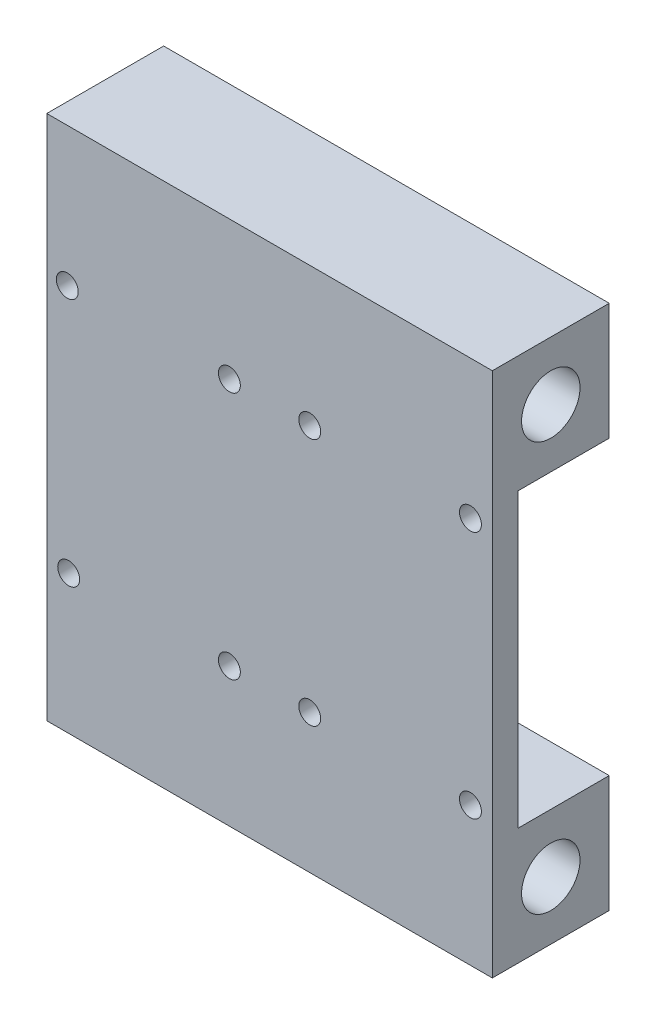
from build123d import *

# Parameters (mm, degrees)
BOSS_EXTRUDE1_DEPTH = 3.5
SKETCH5_W           = 16
SKETCH5_H           = 16
SKETCH5_R           = 4
BOSS_EXTRUDE2_DEPTH = 115
SKETCH8_R           = 1.5
CUT_EXTRUDE1_DEPTH  = 3.5
CUT_EXTRUDE2_DEPTH  = 16


with BuildPart() as part:
    # Sketch1 → Boss-Extrude1 (new body)
    with BuildSketch(Plane.XY):
        Polygon((0, 0), (0, 40), (115, 40), (115, 0), (110, 0), (60, 0), (55, 0), (5, 0), align=None)
    extrude(amount=BOSS_EXTRUDE1_DEPTH)

    # Sketch5 → Boss-Extrude2 (add)
    with BuildSketch(Plane(origin=(115, 0, 0), x_dir=(0, 0, -1), z_dir=(1, 0, 0))):
        with Locations((4.5, 48)):
            Rectangle(SKETCH5_W, SKETCH5_H)
        with Locations((4.5, 48)):
            Circle(SKETCH5_R, mode=Mode.SUBTRACT)
        with Locations((4.5, -8)):
            Rectangle(SKETCH5_W, SKETCH5_H)
        with Locations((4.5, -8)):
            Circle(SKETCH5_R, mode=Mode.SUBTRACT)
    extrude(amount=-BOSS_EXTRUDE2_DEPTH)

    # Sketch8 → Cut-Extrude1 (cut)
    with BuildSketch(Plane(origin=(0, 0, 0), x_dir=(-1, 0, 0), z_dir=(0, 0, -1))):
        with Locations((-107, 37)):
            Circle(SKETCH8_R)
        with Locations((-63, 37)):
            Circle(SKETCH8_R)
        with Locations((-52, 37)):
            Circle(SKETCH8_R)
        with Locations((-8, 37)):
            Circle(SKETCH8_R)
        with Locations((-8, 3)):
            Circle(SKETCH8_R)
        with Locations((-63, 3)):
            Circle(SKETCH8_R)
        with Locations((-52, 3)):
            Circle(SKETCH8_R)
        with Locations((-107, 3)):
            Circle(SKETCH8_R)
        with Locations((-85, 37)):
            Circle(SKETCH8_R)
        with Locations((-29.809705399, 37)):
            Circle(SKETCH8_R)
        with Locations((-30, 3)):
            Circle(SKETCH8_R)
        with Locations((-85, 3)):
            Circle(SKETCH8_R)
    extrude(amount=-CUT_EXTRUDE1_DEPTH, mode=Mode.SUBTRACT)

    # Sketch10 → Cut-Extrude2 (cut)
    with BuildSketch(Plane(origin=(0, 0, -12.5), x_dir=(-1, 0, 0), z_dir=(0, 0, -1))):
        Polygon((-88, 56), (-88, 37), (-88, -16), (-115, -16), (-115, 56), align=None)
        Polygon((-27, 56), (0, 56), (0, -16), (-27, -16), (-27, 37.055783356), align=None)
    extrude(amount=-CUT_EXTRUDE2_DEPTH, mode=Mode.SUBTRACT)


solid = part.part
